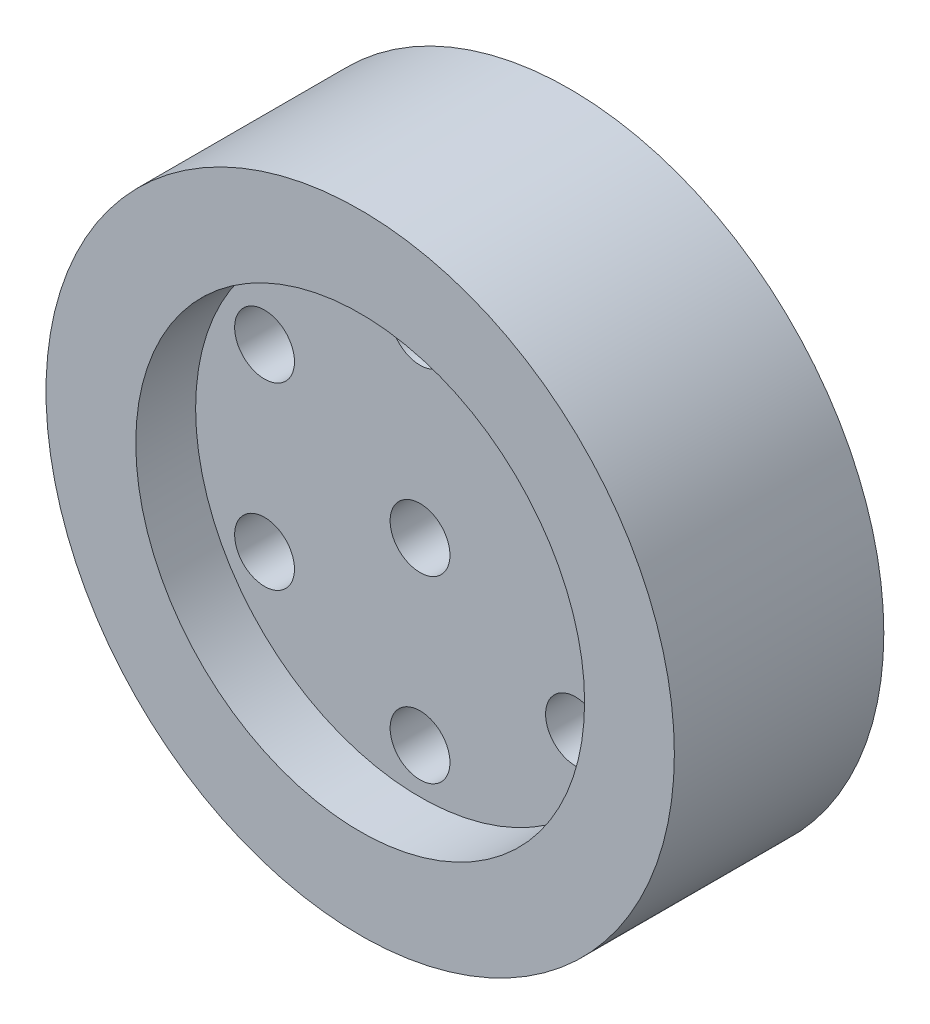
from build123d import *

# Parameters (mm, degrees)
SKETCH1_R           = 21
SKETCH1_R_2         = 2
BOSS_EXTRUDE1_DEPTH = 14
SKETCH2_R           = 15
CUT_EXTRUDE1_DEPTH  = 4
SKETCH3_R           = 15
SKETCH3_R_2         = 5
CUT_EXTRUDE2_DEPTH  = 4


with BuildPart() as part:
    # Sketch1 → Boss-Extrude1 (new body)
    with BuildSketch(Plane.XY):
        Circle(SKETCH1_R)
        with Locations((0, 12)):
            Circle(SKETCH1_R_2, mode=Mode.SUBTRACT)
        with Locations((10.392304845, 6)):
            Circle(SKETCH1_R_2, mode=Mode.SUBTRACT)
        with Locations((10.392304845, -6)):
            Circle(SKETCH1_R_2, mode=Mode.SUBTRACT)
        with Locations((0, -12)):
            Circle(SKETCH1_R_2, mode=Mode.SUBTRACT)
        with Locations((-10.392304845, -6)):
            Circle(SKETCH1_R_2, mode=Mode.SUBTRACT)
        with Locations((-10.392304845, 6)):
            Circle(SKETCH1_R_2, mode=Mode.SUBTRACT)
        Circle(SKETCH1_R_2, mode=Mode.SUBTRACT)
    extrude(amount=BOSS_EXTRUDE1_DEPTH)

    # Sketch2 → Cut-Extrude1 (cut)
    with BuildSketch(Plane.XY.offset(14)):
        Circle(SKETCH2_R)
    extrude(amount=-CUT_EXTRUDE1_DEPTH, mode=Mode.SUBTRACT)

    # Sketch3 → Cut-Extrude2 (cut)
    with BuildSketch(Plane(origin=(0, 0, 0), x_dir=(-1, 0, 0), z_dir=(0, 0, -1))):
        Circle(SKETCH3_R)
        Circle(SKETCH3_R_2, mode=Mode.SUBTRACT)
    extrude(amount=-CUT_EXTRUDE2_DEPTH, mode=Mode.SUBTRACT)


solid = part.part
